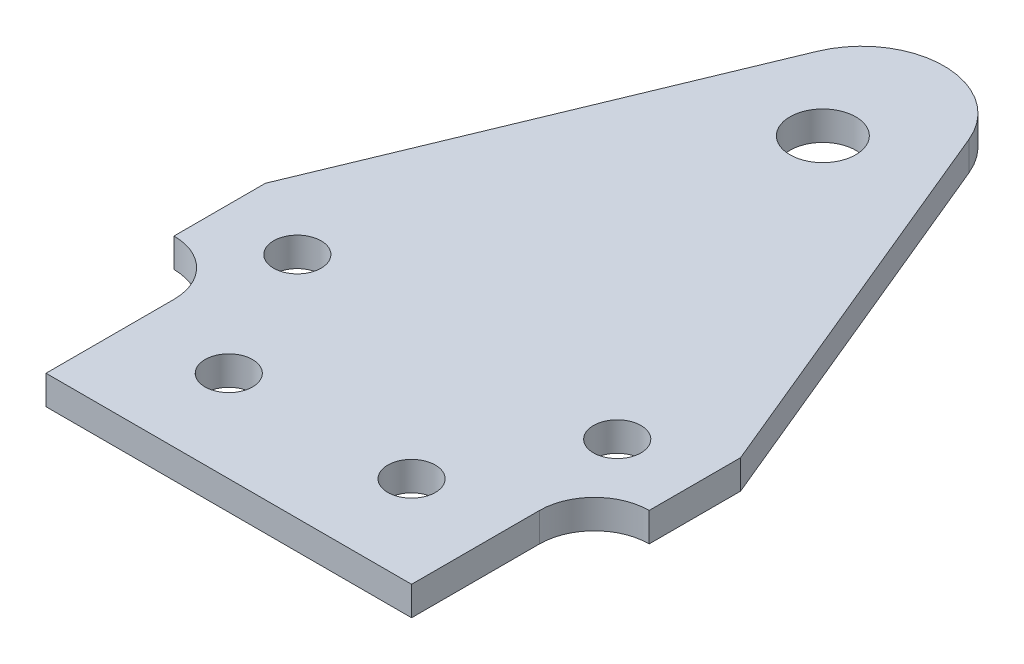
from build123d import *

# Parameters (mm, degrees)
SKETCH1_R           = 2.6
SKETCH1_R_2         = 3.6
BOSS_EXTRUDE1_DEPTH = 3.175


with BuildPart() as part:
    # Sketch1 → Boss-Extrude1 (new body)
    with BuildSketch(Plane(origin=(0, 0, 0), x_dir=(1, 0, 0), z_dir=(0, 1, 0))):
        with BuildLine():
            Line((8.314915793, 72.695604767), (26, 30.000034622))
            Line((26, 30.000034622), (26, 20.000034622))
            ThreePointArc((26, 20.000034622), (21.757357213, 18.242652928), (20, 14))
            Line((20, 14), (20, 0))
            Line((20, 0), (-20, 0))
            Line((-20, 0), (-20, 14))
            ThreePointArc((-20, 14), (-21.757357213, 18.242652928), (-26, 20.000034622))
            Line((-26, 20.000034622), (-26, 30.000034622))
            Line((-26, 30.000034622), (-8.314915793, 72.695604767))
            ThreePointArc((-8.314915793, 72.695604767), (0, 78.251453876), (8.314915793, 72.695604767))
        make_face()
        with Locations((10, 10)):
            Circle(SKETCH1_R, mode=Mode.SUBTRACT)
        with Locations((-17.5, 25)):
            Circle(SKETCH1_R, mode=Mode.SUBTRACT)
        with Locations((0, 65)):
            Circle(SKETCH1_R_2, mode=Mode.SUBTRACT)
        with Locations((17.5, 25)):
            Circle(SKETCH1_R, mode=Mode.SUBTRACT)
        with Locations((-10, 10)):
            Circle(SKETCH1_R, mode=Mode.SUBTRACT)
    extrude(amount=BOSS_EXTRUDE1_DEPTH)


solid = part.part
